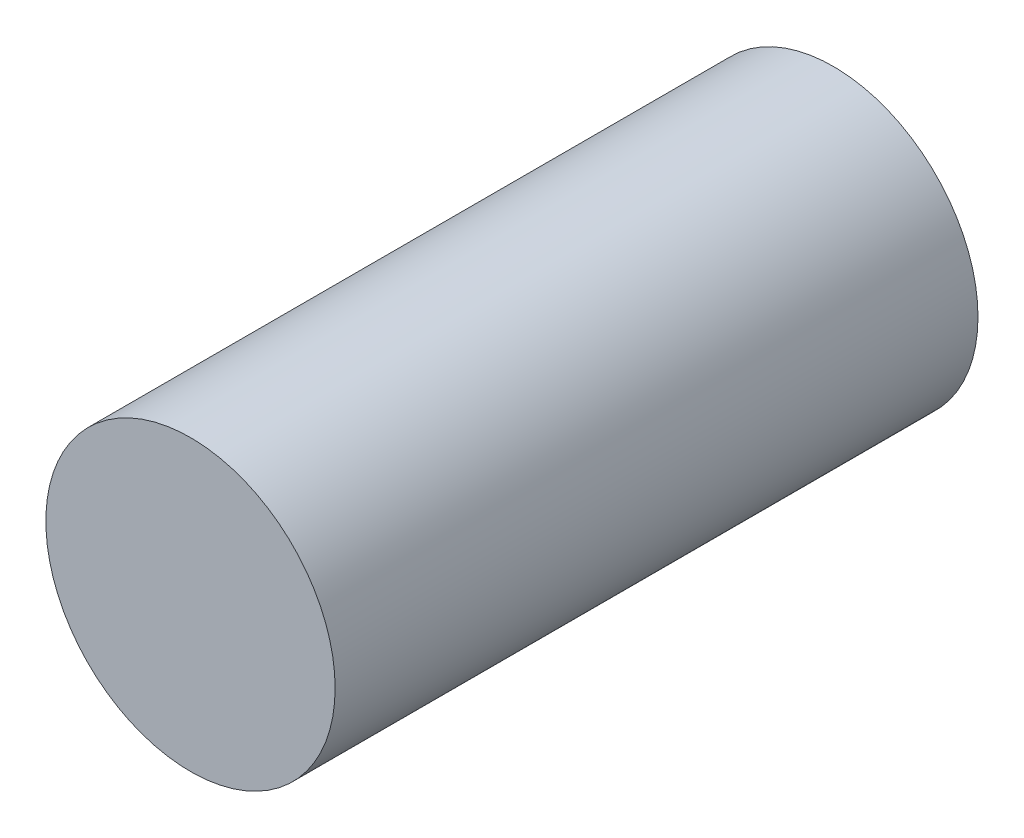
from build123d import *

# Parameters (mm, degrees)
SKETCH1_R           = 4.5
BOSS_EXTRUDE1_DEPTH = 20
SKETCH2_R           = 1
CUT_EXTRUDE1_DEPTH  = 15


with BuildPart() as part:
    # Sketch1 → Boss-Extrude1 (new body)
    with BuildSketch(Plane.XY):
        Circle(SKETCH1_R)
    extrude(amount=BOSS_EXTRUDE1_DEPTH)

    # Sketch2 → Cut-Extrude1 (cut)
    with BuildSketch(Plane.XY):
        Circle(SKETCH2_R)
    extrude(amount=CUT_EXTRUDE1_DEPTH, mode=Mode.SUBTRACT)


solid = part.part
